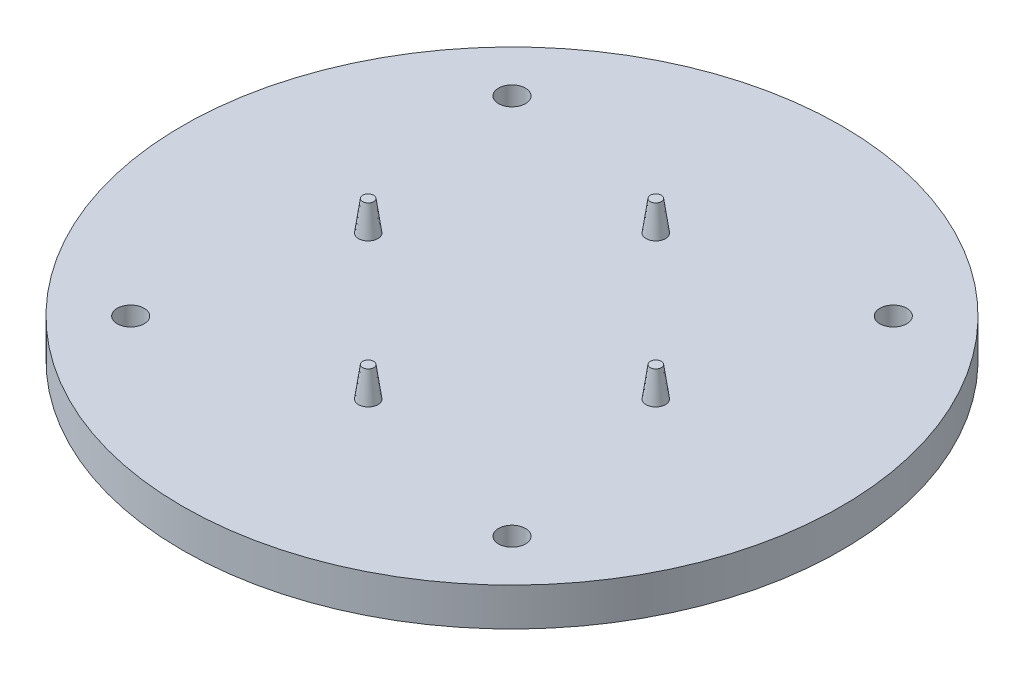
from build123d import *

# Parameters (mm, degrees)
SKETCH1_R            = 55
BOSS_EXTRUDE1_DEPTH  = 6.35
SKETCH2_R            = 1.625
BOSS_EXTRUDE2_DEPTH  = 5
BOSS_EXTRUDE2_TAPER  = 8
M4_CLEARANCE_HOLE1_D = 4.5


with BuildPart() as part:
    # Sketch1 → Boss-Extrude1 (new body)
    with BuildSketch(Plane(origin=(0, 0, 0), x_dir=(1, 0, 0), z_dir=(0, 1, 0))):
        Circle(SKETCH1_R)
    extrude(amount=BOSS_EXTRUDE1_DEPTH)

    # Sketch2 → Boss-Extrude2 (add)
    with BuildSketch(Plane(origin=(0, 6.35, 0), x_dir=(1, 0, 0), z_dir=(0, 1, 0))):
        with Locations((0, -24)):
            Circle(SKETCH2_R)
        with Locations((-24, 0)):
            Circle(SKETCH2_R)
        with Locations((0, 24)):
            Circle(SKETCH2_R)
        with Locations((24, 0)):
            Circle(SKETCH2_R)
    extrude(amount=BOSS_EXTRUDE2_DEPTH, taper=BOSS_EXTRUDE2_TAPER)

    # M4 Clearance Hole1 (through all)
    with Locations(Plane(origin=(0, 6.35, 0), x_dir=(1, 0, 0), z_dir=(0, 1, 0))):
        with Locations((-31.819805153, 31.819805153), (31.819805153, 31.819805153), (31.819805153, -31.819805153), (-31.819805153, -31.819805153)):
            Hole(M4_CLEARANCE_HOLE1_D / 2)


solid = part.part
